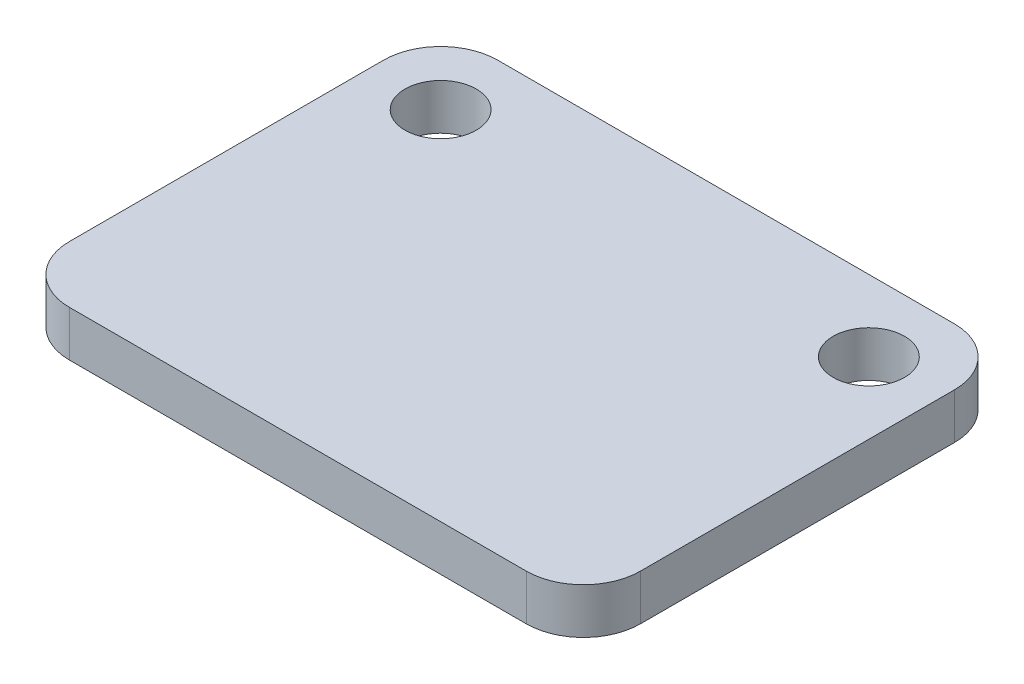
from build123d import *

# Parameters (mm, degrees)
SKETCH1_W           = 20
SKETCH1_H           = 15
SKETCH1_R           = 1.25
BOSS_EXTRUDE1_DEPTH = 1.6
FILLET1_R           = 2


with BuildPart() as part:
    # Sketch1 → Boss-Extrude1 (new body)
    with BuildSketch(Plane(origin=(0, 0, 0), x_dir=(1, 0, 0), z_dir=(0, 1, 0))):
        Rectangle(SKETCH1_W, SKETCH1_H)
        with Locations((-7.5, 5)):
            Circle(SKETCH1_R, mode=Mode.SUBTRACT)
        with Locations((7.5, 5)):
            Circle(SKETCH1_R, mode=Mode.SUBTRACT)
    extrude(amount=BOSS_EXTRUDE1_DEPTH)

    # Fillet1
    fillet1_edges = [part.edges().sort_by_distance(p)[0] for p in [
        (-10, 0.8, -7.5),
        (10, 0.8, -7.5),
        (10, 0.8, 7.5),
        (-10, 0.8, 7.5),
    ]]
    fillet(fillet1_edges, radius=FILLET1_R)


solid = part.part
